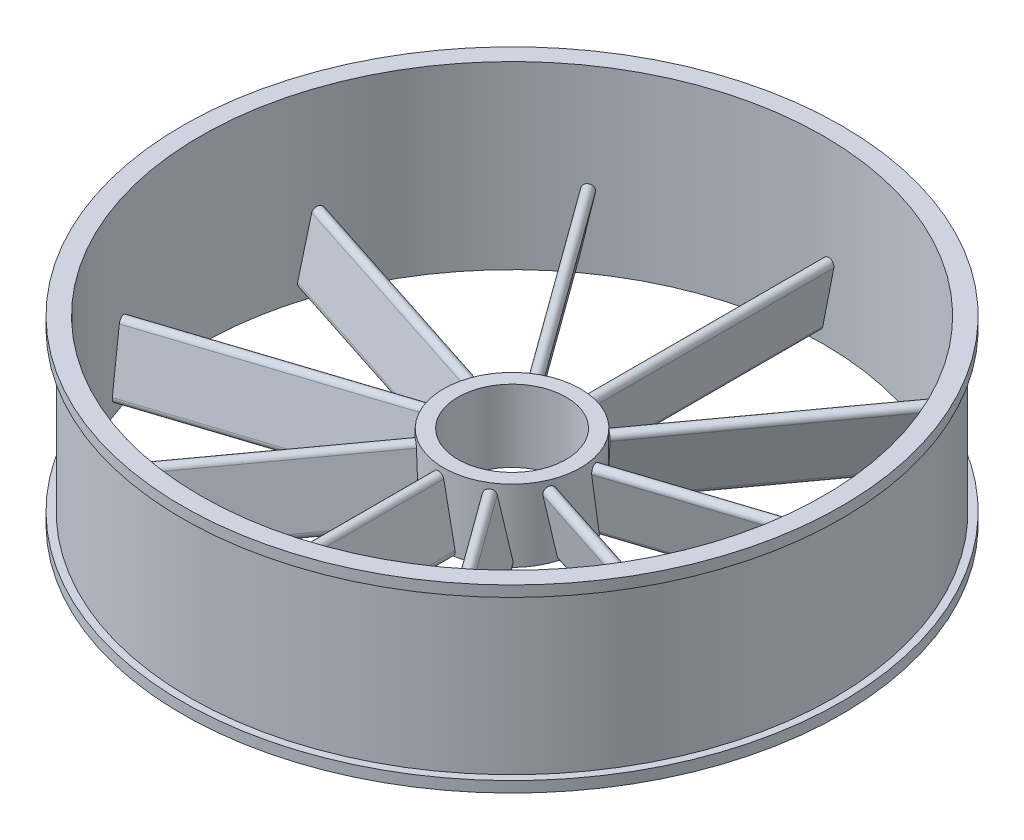
from build123d import *

# Parameters (mm, degrees)
ESQUISSE3_W                  = 40
ESQUISSE3_H                  = 200
BOSS_EXTRU_1_DEPTH           = 674.281499
R_P_TITION_CIRCULAIRE1_COUNT = 10


with BuildPart() as part:
    # Esquisse1 → Révolution1 (revolve)
    with BuildSketch(Plane.XY):
        Polygon((-894.281498485, 25.08546357), (-894.281498485, 465.08546357), (-914.281498485, 465.08546357), (-914.281498485, 495.08546357), (-864.281498485, 495.08546357), (-864.281498485, -4.91453643), (-914.281498485, -4.91453643), (-914.281498485, 25.08546357), align=None)
    revolve(axis=Axis((0, 0, 0), (0, 1, 0)))

    # Esquisse7 → Boss.-Extru.1 (add)
    with BuildSketch(Plane(origin=(0, 225.08546357, -190), x_dir=(-1, 0, 0), z_dir=(0, 0, -1))):
        with BuildLine():
            Line((2.553355541, -189.252070408), (-28.825226081, -32.359162298))
            ThreePointArc((-28.825226081, -32.359162298), (-17.058257973, -14.708710135), (0.59219419, -26.475678244))
            Line((0.59219419, -26.475678244), (31.970775812, -183.368586354))
            ThreePointArc((31.970775812, -183.368586354), (20.203807703, -201.019038517), (2.553355541, -189.252070408))
        make_face()
    boss_extru_1 = extrude(amount=BOSS_EXTRU_1_DEPTH)

    # Répétition circulaire1: Boss.-Extru.1 ×10 about axis
    r_p_tition_circulaire1_axis = Axis((0, 0, 0), (0, 1, 0))
    for i in range(1, R_P_TITION_CIRCULAIRE1_COUNT):
        add(boss_extru_1.rotate(r_p_tition_circulaire1_axis, i * 360 / R_P_TITION_CIRCULAIRE1_COUNT))


with BuildPart() as body_2:
    # Esquisse3 → Révolution3 (revolve)
    with BuildSketch(Plane.XY):
        with Locations((-170, 125.08546357)):
            Rectangle(ESQUISSE3_W, ESQUISSE3_H)
    revolve(axis=Axis((0, -352.296373017, 0), (0, 1, 0)))


solid = Compound([part.part, body_2.part])
